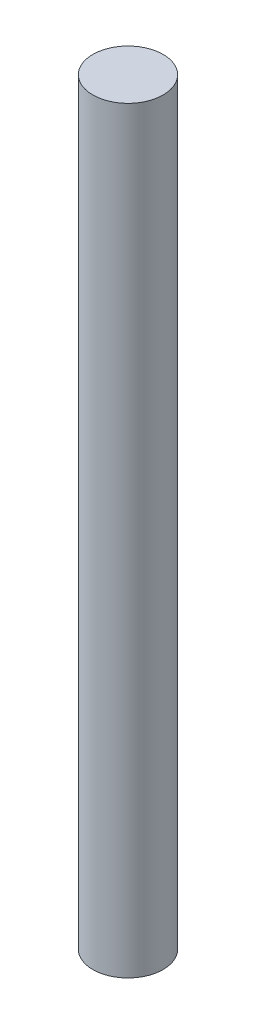
from build123d import *

# Parameters (mm, degrees)
SKETCH1_R           = 4
BOSS_EXTRUDE1_DEPTH = 95
SKETCH2_R           = 4
CUT_EXTRUDE1_DEPTH  = 8.75


with BuildPart() as part:
    # Sketch1 → Boss-Extrude1 (new body)
    with BuildSketch(Plane(origin=(0, 0, 0), x_dir=(1, 0, 0), z_dir=(0, 1, 0))):
        Circle(SKETCH1_R)
    extrude(amount=BOSS_EXTRUDE1_DEPTH)

    # Sketch2 → Cut-Extrude1 (cut)
    with BuildSketch(Plane(origin=(0, 95, 0), x_dir=(1, 0, 0), z_dir=(0, 1, 0))):
        Circle(SKETCH2_R)
    extrude(amount=-CUT_EXTRUDE1_DEPTH, mode=Mode.SUBTRACT)


solid = part.part
